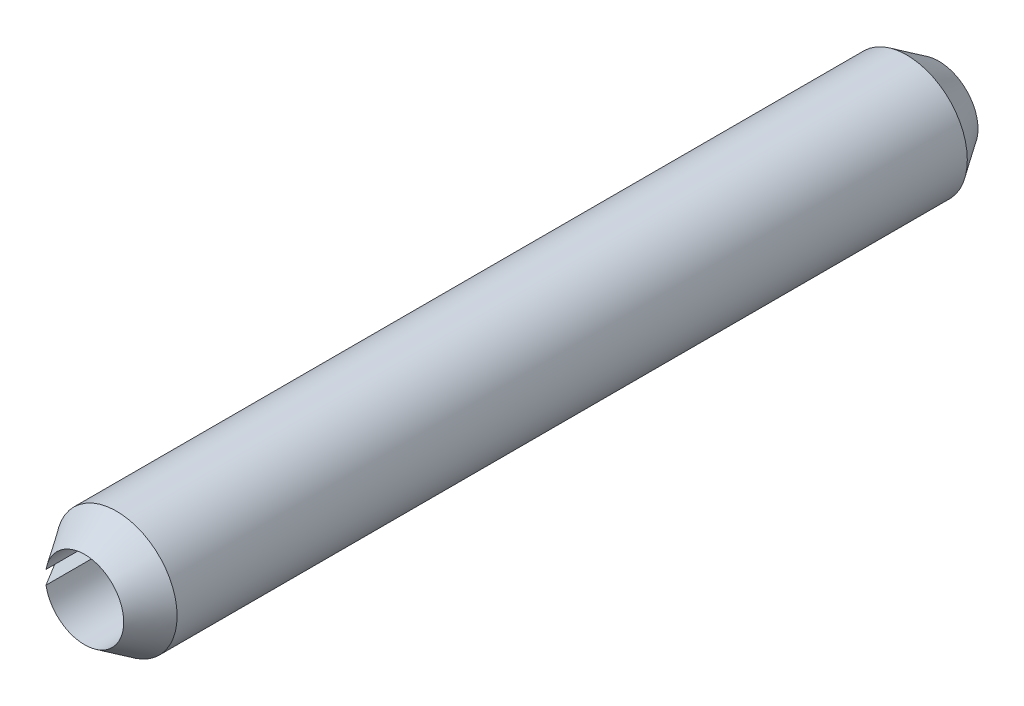
from build123d import *

# Parameters (mm, degrees)
EXTRUDE1_DEPTH = 6


with BuildPart() as part:
    # Sketch1 → Extrude1 (new body, symmetric)
    with BuildSketch(Plane.XY):
        with BuildLine():
            Line((-0.83708659, 0.147600951), (-0.541644264, 0.095506498))
            ThreePointArc((-0.541644264, 0.095506498), (0.55, 0), (-0.541644264, -0.095506498))
            Line((-0.541644264, -0.095506498), (-0.83708659, -0.147600951))
            ThreePointArc((-0.83708659, -0.147600951), (0.85, 0), (-0.83708659, 0.147600951))
        make_face()
    extrude(amount=EXTRUDE1_DEPTH, both=True)

    # Sketch2 → Cut-Revolve1 (revolve, cut)
    with BuildSketch(Plane(origin=(0, 0, 0), x_dir=(0, 0, -1), z_dir=(1, 0, 0))):
        Polygon((6, 0.85), (6, 0.55), (5.55, 0.85), align=None)
        Polygon((-5.55, 0.85), (-6, 0.85), (-6, 0.55), align=None)
    revolve(axis=Axis((0, 0, -6), (0, 0, 1)), mode=Mode.SUBTRACT)


solid = part.part
